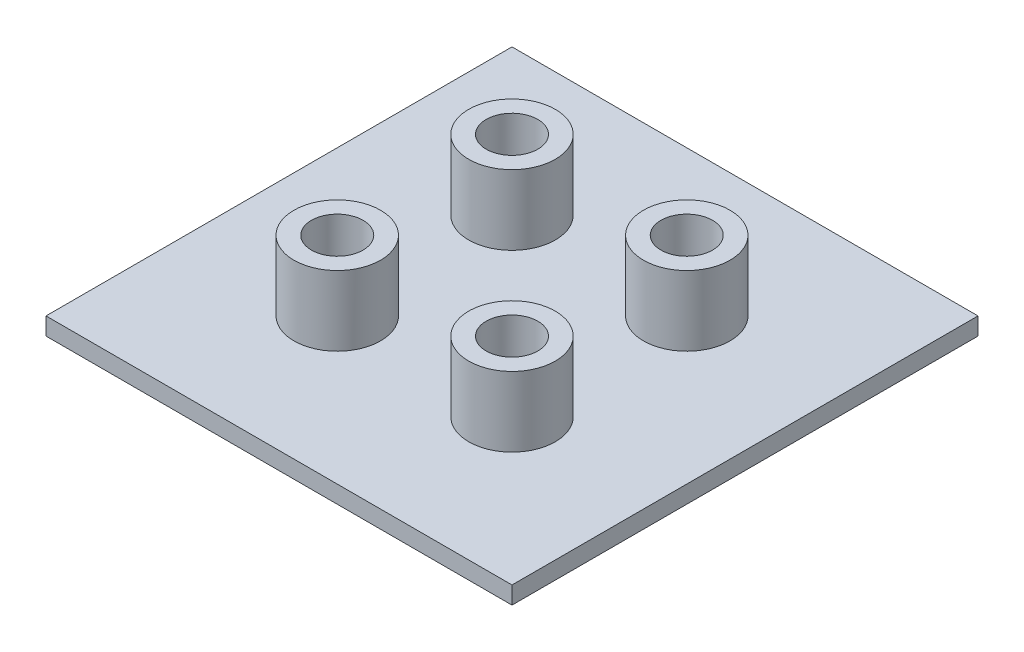
from build123d import *

# Parameters (mm, degrees)
SKETCH1_W                 = 80
SKETCH1_H                 = 80
BOSS_EXTRUDE1_DEPTH       = 3
SKETCH2_R                 = 7.435
SKETCH2_R_2               = 4.435
BOSS_EXTRUDE2_DEPTH       = 12
MIRROR2_COPY_1_SKETCH_R   = 7.435
MIRROR2_COPY_1_SKETCH_R_2 = 4.435
MIRROR2_COPY_1_DEPTH      = 12


with BuildPart() as part:
    # Sketch1 → Boss-Extrude1 (new body)
    with BuildSketch(Plane(origin=(0, 0, 0), x_dir=(1, 0, 0), z_dir=(0, 1, 0))):
        Rectangle(SKETCH1_W, SKETCH1_H)
    extrude(amount=BOSS_EXTRUDE1_DEPTH)

    # Sketch2 → Boss-Extrude2 (add)
    with BuildSketch(Plane(origin=(0, 3, 0), x_dir=(1, 0, 0), z_dir=(0, 1, 0))):
        with Locations(Location((-15, -15, 0), (0, 0, 90))):  # turned: the seam where the file's is
            Circle(SKETCH2_R)
        with Locations(Location((-15, -15, 0), (0, 0, 270))):  # turned: the seam where the file's is
            Circle(SKETCH2_R_2, mode=Mode.SUBTRACT)
    boss_extrude2 = extrude(amount=BOSS_EXTRUDE2_DEPTH)

    # Mirror1: Boss-Extrude2 across plane
    add(boss_extrude2.mirror(Plane.XY))

    # Mirror2: Boss-Extrude2 across plane
    add(boss_extrude2.mirror(Plane(origin=(0, 0, 0), x_dir=(0, 0, 1), z_dir=(1, 0, 0))))

    # Mirror2 copy 1 sketch → Mirror2 copy 1 (add)
    with BuildSketch(Plane(origin=(0, 3, 0), x_dir=(-1, 0, 0), z_dir=(0, 1, 0))):
        with Locations(Location((-15, -15, 0), (0, 0, 90))):  # turned: the seam where the file's is
            Circle(MIRROR2_COPY_1_SKETCH_R)
        with Locations(Location((-15, -15, 0), (0, 0, 270))):  # turned: the seam where the file's is
            Circle(MIRROR2_COPY_1_SKETCH_R_2, mode=Mode.SUBTRACT)
    extrude(amount=MIRROR2_COPY_1_DEPTH)


solid = part.part
